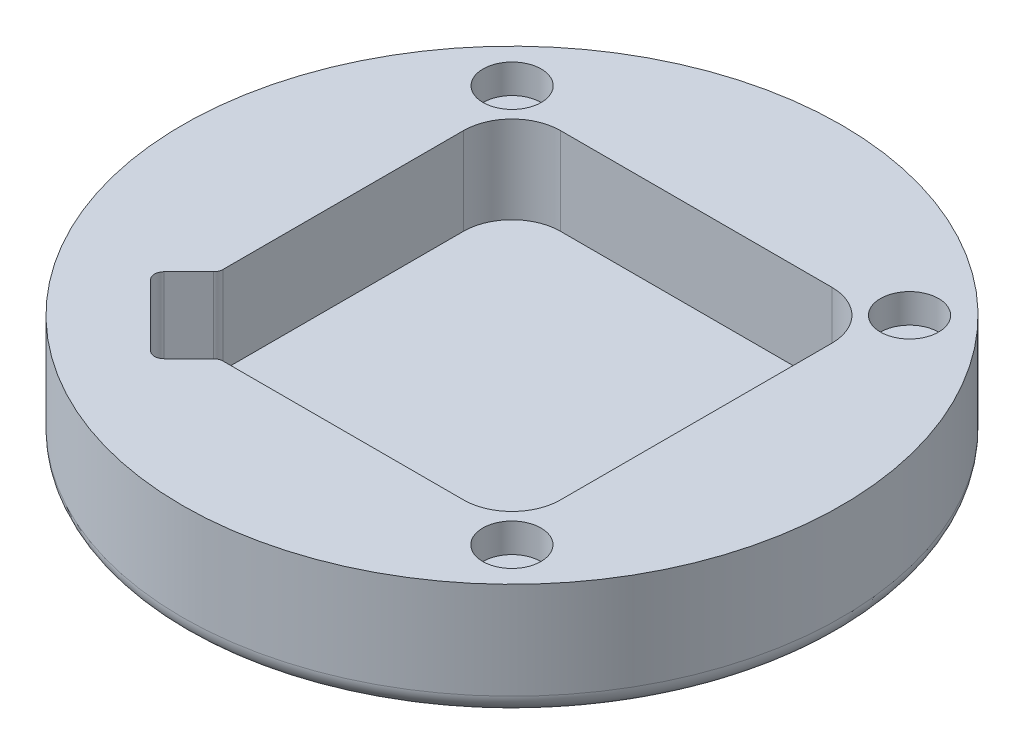
from build123d import *

# Parameters (mm, degrees)
SKETCH1_R           = 34
BOSS_EXTRUDE1_DEPTH = 3
SKETCH2_R           = 34
SKETCH2_W           = 38
SKETCH2_H           = 38
BOSS_EXTRUDE2_DEPTH = 9
FILLET1_R           = 5
SKETCH3_R           = 3
CUT_EXTRUDE1_DEPTH  = 3
CUT_EXTRUDE2_DEPTH  = 9
FILLET2_R           = 1
FILLET3_R           = 2


with BuildPart() as part:
    # Sketch1 → Boss-Extrude1 (new body)
    with BuildSketch(Plane(origin=(0, 0, 0), x_dir=(1, 0, 0), z_dir=(0, 1, 0))):
        Circle(SKETCH1_R)
    extrude(amount=BOSS_EXTRUDE1_DEPTH)

    # Sketch2 → Boss-Extrude2 (add)
    with BuildSketch(Plane(origin=(0, 3, 0), x_dir=(1, 0, 0), z_dir=(0, 1, 0))):
        Circle(SKETCH2_R)
        Rectangle(SKETCH2_W, SKETCH2_H, mode=Mode.SUBTRACT)
    extrude(amount=BOSS_EXTRUDE2_DEPTH)

    # Fillet1
    fillet1_edges = [part.edges().sort_by_distance(p)[0] for p in [
        (19, 7.5, -19),
        (-19, 7.5, -19),
        (-19, 7.5, 19),
        (19, 7.5, 19),
    ]]
    fillet(fillet1_edges, radius=FILLET1_R)

    # Sketch3 → Cut-Extrude1 (cut)
    with BuildSketch(Plane(origin=(0, 12, 0), x_dir=(1, 0, 0), z_dir=(0, 1, 0))):
        with Locations((-20.5, 20.512191497)):
            Circle(SKETCH3_R)
        with Locations((20.512191497, 20.5)):
            Circle(SKETCH3_R)
        with Locations((20.5, -20.512191497)):
            Circle(SKETCH3_R)
    extrude(amount=-CUT_EXTRUDE1_DEPTH, mode=Mode.SUBTRACT)

    # Sketch4 → Cut-Extrude2 (cut)
    with BuildSketch(Plane(origin=(0, 12, 0), x_dir=(1, 0, 0), z_dir=(0, 1, 0))):
        Polygon((-19, -11.221825407), (-22.535533906, -14.757359313), (-17.139357786, -20.153535433), (-14.757359313, -22.535533906), (-11.221825407, -19), align=None)
    extrude(amount=-CUT_EXTRUDE2_DEPTH, mode=Mode.SUBTRACT)

    # Fillet2
    fillet2_edges = [part.edges().sort_by_distance(p)[0] for p in [
        (-19, 7.5, 11.221825407),
        (-11.221825407, 7.5, 19),
        (-14.757359313, 7.5, 22.535533906),
        (-22.535533906, 7.5, 14.757359313),
    ]]
    fillet(fillet2_edges, radius=FILLET2_R)

    # Fillet3
    fillet3_edges = [part.edges().sort_by_distance(p)[0] for p in [
        (-34, 0, 0),
    ]]
    fillet(fillet3_edges, radius=FILLET3_R)


solid = part.part
